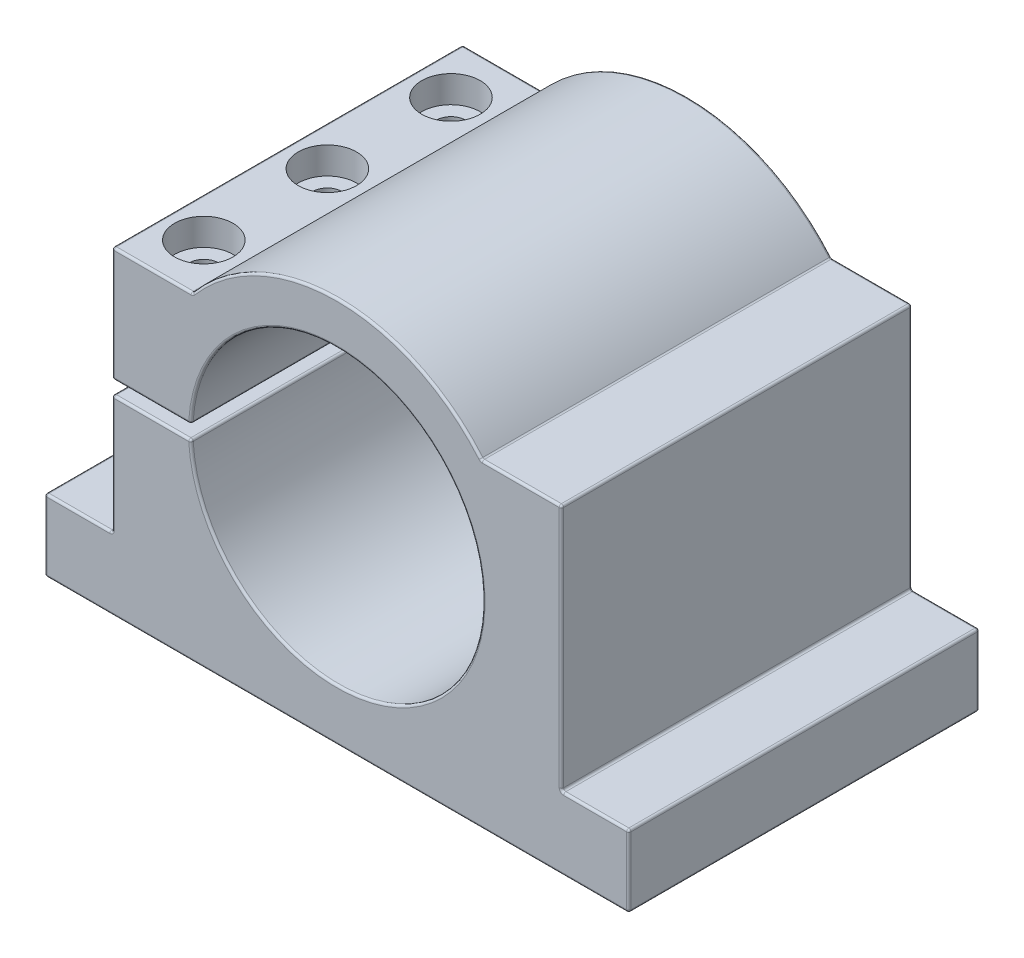
from build123d import *

# Parameters (mm, degrees)
EXTRUDE_1_DEPTH     = 39
SKETCH_2_R          = 6.5
CUT_EXTRUDE_1_DEPTH = 6
SKETCH_3_R          = 3.25
CUT_EXTRUDE_2_DEPTH = 22.5
SKETCH_4_R          = 2.1
CUT_EXTRUDE_3_DEPTH = 30
FILLET_1_R          = 0.5


with BuildPart() as part:
    # Эскиз1 → Бобышка-Вытянуть1 (new body, symmetric)
    with BuildSketch(Plane.XY):
        with BuildLine():
            Line((-65, -44), (65, -44))
            Line((65, -44), (65, -28))
            Line((65, -28), (50, -28))
            Line((50, -28), (50, 27))
            Line((50, 27), (32.171415884, 27))
            ThreePointArc((32.171415884, 27), (0, 42), (-32.171415884, 27))
            Line((-32.171415884, 27), (-50, 27))
            Line((-50, 27), (-50, 1.5))
            Line((-50, 1.5), (-32.465366161, 1.5))
            ThreePointArc((-32.465366161, 1.5), (32.5, 0), (-32.465366161, -1.5))
            Line((-32.465366161, -1.5), (-50, -1.5))
            Line((-50, -1.5), (-50, -28))
            Line((-50, -28), (-65, -28))
            Line((-65, -28), (-65, -44))
        make_face()
    extrude(amount=EXTRUDE_1_DEPTH, both=True)

    # Эскиз2 → Вырез-Вытянуть1 (cut)
    with BuildSketch(Plane(origin=(0, 27, 0), x_dir=(1, 0, 0), z_dir=(0, 1, 0))):
        with Locations((-41.085707942, 27.5)):
            Circle(SKETCH_2_R)
        with Locations((-41.085707942, 0)):
            Circle(SKETCH_2_R)
        with Locations((-41.085707942, -27.5)):
            Circle(SKETCH_2_R)
    extrude(amount=-CUT_EXTRUDE_1_DEPTH, mode=Mode.SUBTRACT)

    # Эскиз3 → Вырез-Вытянуть2 (cut)
    with BuildSketch(Plane(origin=(0, 21, 0), x_dir=(1, 0, 0), z_dir=(0, 1, 0))):
        with Locations((-41.085707942, 27.5)):
            Circle(SKETCH_3_R)
        with Locations((-41.085707942, 0)):
            Circle(SKETCH_3_R)
        with Locations((-41.085707942, -27.5)):
            Circle(SKETCH_3_R)
    extrude(amount=-CUT_EXTRUDE_2_DEPTH, mode=Mode.SUBTRACT)

    # Эскиз4 → Вырез-Вытянуть3 (cut)
    with BuildSketch(Plane(origin=(0, -1.5, 0), x_dir=(1, 0, 0), z_dir=(0, 1, 0))):
        with Locations((-41.085707942, 27.5)):
            Circle(SKETCH_4_R)
        with Locations((-41.085707942, 0)):
            Circle(SKETCH_4_R)
        with Locations((-41.085707942, -27.5)):
            Circle(SKETCH_4_R)
    extrude(amount=-CUT_EXTRUDE_3_DEPTH, mode=Mode.SUBTRACT)

    # Скругление1
    fillet_1_edges = [part.edges().sort_by_distance(p)[0] for p in [
        (-41.085707942, 27, 39),
        (50, -0.5, -39),
        (57.5, -28, -39),
        (65, -36, -39),
        (-50, 14.25, 39),
        (0, -44, -39),
        (-65, -36, -39),
        (-57.5, -28, -39),
        (-50, -14.75, -39),
        (-41.232683081, -1.5, -39),
        (32.5, 0, -39),
        (-41.232683081, 1.5, -39),
        (-50, 14.25, -39),
        (-41.232683081, 1.5, 39),
        (-41.085707942, 27, -39),
        (0, 42, -39),
        (41.085707942, 27, -39),
        (32.5, 0, 39),
        (50, 27, 0),
        (50, -28, 0),
        (65, -28, 0),
        (65, -44, 0),
        (-65, -44, 0),
        (-65, -28, 0),
        (-50, -28, 0),
        (-50, -1.5, 0),
        (-32.465366161, -1.5, 0),
        (-32.465366161, 1.5, 0),
        (-50, 1.5, 0),
        (-50, 27, 0),
        (-32.171415884, 27, 0),
        (32.171415884, 27, 0),
        (-41.232683081, -1.5, 39),
        (-50, -14.75, 39),
        (-57.5, -28, 39),
        (41.085707942, 27, 39),
        (-65, -36, 39),
        (0, -44, 39),
        (65, -36, 39),
        (57.5, -28, 39),
        (50, -0.5, 39),
        (0, 42, 39),
    ]]
    fillet(fillet_1_edges, radius=FILLET_1_R)


solid = part.part
